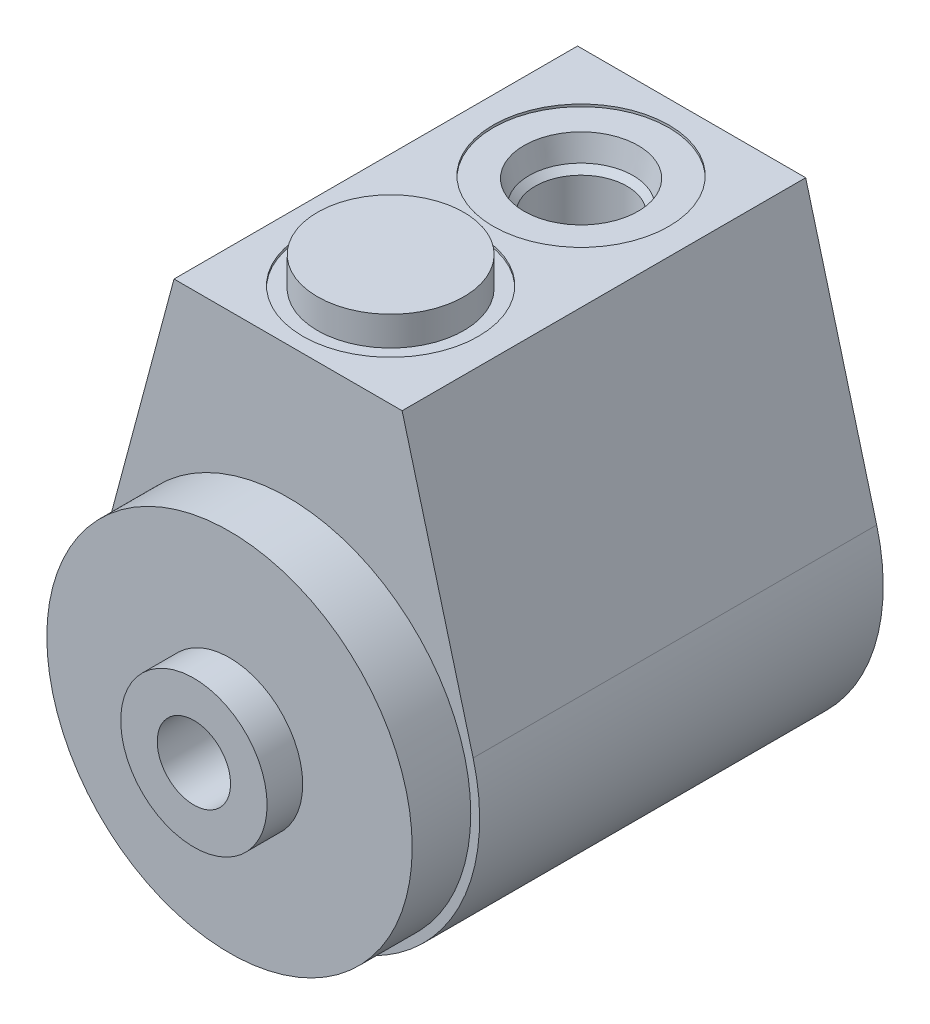
from build123d import *

# Parameters (mm, degrees)
EXTRUDE1_DEPTH    = 43.7642
HOLE1_D           = 19.05
HOLE1_DEPTH       = 0.254
HOLE2_D           = 20.574
HOLE2_DEPTH       = 4.826
SKETCH6_W         = 7.9375
SKETCH6_H         = 0.9906
SKETCH8_W         = 7.9375
SKETCH8_H         = 3.175
HOLE3_D           = 5.1816
HOLE3_DEPTH       = 10.922
CIRPATTERN1_COUNT = 2


with BuildPart() as part:
    # Sketch1 → Extrude1 (new body)
    with BuildSketch(Plane.XY.offset(43.7642)):
        with BuildLine():
            Line((20.070420221, 5.373106363), (12.3698, 34.1376))
            Line((12.3698, 34.1376), (-12.3698, 34.1376))
            Line((-12.3698, 34.1376), (-20.070420221, 5.373106363))
            ThreePointArc((-20.070420221, 5.373106363), (0, -20.7772), (20.070420221, 5.373106363))
        make_face()
    extrude(amount=-EXTRUDE1_DEPTH)

    # Hole1
    with Locations(Plane(origin=(0, 34.1376, 0), x_dir=(-1, 0, 0), z_dir=(0, 1, 0))):
        with Locations((0, 32.639)):
            Hole(HOLE1_D / 2, depth=HOLE1_DEPTH)

    # Hole2
    with Locations(Plane(origin=(0, 0, 0), x_dir=(-1, 0, 0), z_dir=(0, 0, -1))):
        with Locations((0, 0)):
            Hole(HOLE2_D / 2, depth=HOLE2_DEPTH)

    # Sketch7 → Revolve2 (revolve)
    with BuildSketch(Plane.XZ):
        Polygon((7.9375, 53.975), (0, 53.975), (0, 43.7642), (19.812, 43.7642), (19.812, 50.1142), (7.9375, 50.1142), align=None)
    revolve(axis=Axis((0, 0, 0), (0, 0, 1)))

    # Sketch6 → Revolve1 (revolve)
    with BuildSketch(Plane.XZ):
        with Locations((3.96875, 4.3307)):
            Rectangle(SKETCH6_W, SKETCH6_H)
    revolve(axis=Axis((0, 0, 0), (0, 0, 1)))

    # Sketch8 → Revolve3 (revolve)
    with BuildSketch(Plane(origin=(0, 0, 32.639), x_dir=(-1, 0, 0), z_dir=(0, 0, -1)), mode=Mode.PRIVATE) as revolve3_sk:
        with Locations((-3.96875, 35.4711)):
            Rectangle(SKETCH8_W, SKETCH8_H)
    revolve(revolve3_sk.sketch.rotate(Axis((0, 0, 32.639), (0, 1, 0)), 270), axis=Axis((0, 0, 32.639), (0, 1, 0)))  # turned: the seam where the file's is

    # Sketch9 → Cut-Revolve1 (revolve, cut)
    with BuildSketch(Plane(origin=(0, 0, 11.9888), x_dir=(-1, 0, 0), z_dir=(0, 0, -1)), mode=Mode.PRIVATE) as cut_revolve1_sk:
        Polygon((-4.9784, 13.3096), (0, 13.3096), (0, 34.1376), (-9.525, 34.1376), (-9.525, 33.8836), (-6.1849, 33.8836), (-5.642306865, 31.3309), (-4.9784, 30.666993135), align=None)
    revolve(cut_revolve1_sk.sketch.rotate(Axis((0, 13.3096, 11.9888), (0, 1, 0)), 270), axis=Axis((0, 13.3096, 11.9888), (0, 1, 0)), mode=Mode.SUBTRACT)  # turned: the seam where the file's is

    # Sketch10 → Cut-Revolve2 (revolve, cut)
    with BuildSketch(Plane.XY.offset(32.639), mode=Mode.PRIVATE) as cut_revolve2_sk:
        Polygon((6.1849, 33.8836), (0, 33.8836), (0, 20.4216), (4.9784, 20.4216), (4.9784, 30.666993135), (5.642306865, 31.3309), align=None)
    revolve(cut_revolve2_sk.sketch.rotate(Axis((0, 33.8836, 32.639), (0, -1, 0)), 270), axis=Axis((0, 33.8836, 32.639), (0, -1, 0)), mode=Mode.SUBTRACT)  # turned: the seam where the file's is

    # Hole3
    with Locations(Plane(origin=(0, 0, 0), x_dir=(-1, 0, 0), z_dir=(0, 0, -1))):
        with Locations((-15.875, 0)):
            hole3 = Hole(HOLE3_D / 2, depth=HOLE3_DEPTH)

    # CirPattern1: Hole3 ×2 about axis
    cirpattern1_axis = Axis((0, 0, 0), (0, 0, 1))
    for i in range(1, CIRPATTERN1_COUNT):
        add(hole3.rotate(cirpattern1_axis, i * 360 / CIRPATTERN1_COUNT), mode=Mode.SUBTRACT)

    # Sketch15 → Hole5 (revolve, cut)
    with BuildSketch(Plane(origin=(0, 0, 3.8354), x_dir=(0, 1, 0), z_dir=(1, 0, 0))):
        Polygon((0, 0), (0, 50.1396), (3.9751, 50.1396), (3.9751, 35.761676477), (5.1562, 35.052), (5.1562, 0), align=None)
    revolve(axis=Axis((0, 0, -2.294623899), (0, 0, 1)), mode=Mode.SUBTRACT)


solid = part.part
